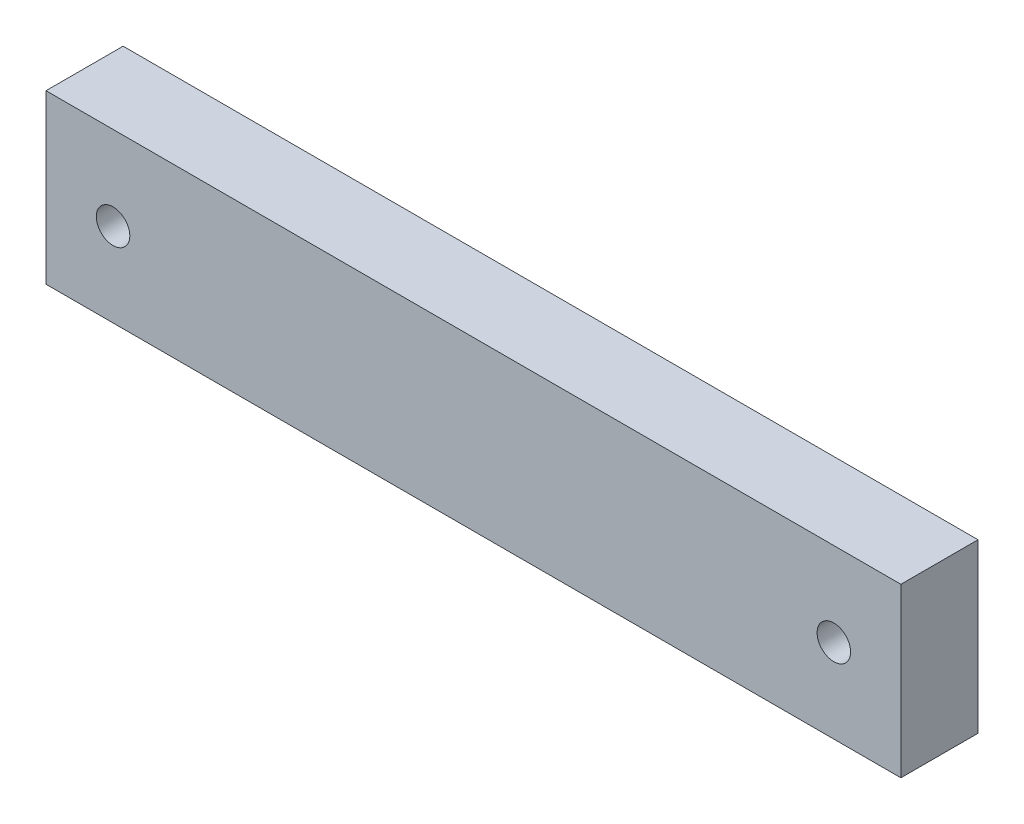
from build123d import *

# Parameters (mm, degrees)
SKETCH1_W           = 255
SKETCH1_H           = 50
SKETCH1_R           = 5
BOSS_EXTRUDE2_DEPTH = 23


with BuildPart() as part:
    # Sketch1 → Boss-Extrude2 (new body)
    with BuildSketch(Plane.XY):
        Rectangle(SKETCH1_W, SKETCH1_H)
        with Locations((-107.5, 0)):
            Circle(SKETCH1_R, mode=Mode.SUBTRACT)
        with Locations((107.5, 0)):
            Circle(SKETCH1_R, mode=Mode.SUBTRACT)
    extrude(amount=BOSS_EXTRUDE2_DEPTH)


solid = part.part
